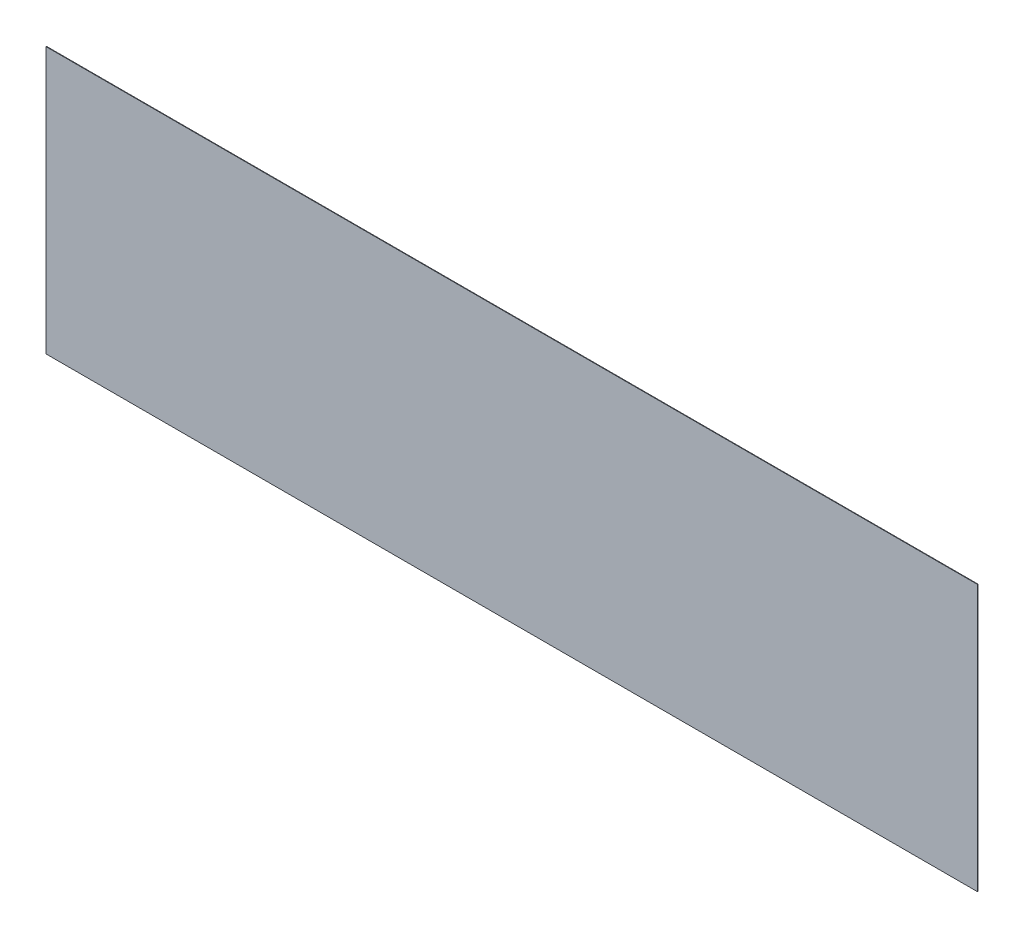
from build123d import *

# Parameters (mm, degrees)
SKETCH1_W           = 70
SKETCH1_H           = 20
BOSS_EXTRUDE1_DEPTH = 0.04


with BuildPart() as part:
    # Sketch1 → Boss-Extrude1 (new body)
    with BuildSketch(Plane.XY):
        with Locations((8.028485757, 4.430284858)):
            Rectangle(SKETCH1_W, SKETCH1_H)
    extrude(amount=BOSS_EXTRUDE1_DEPTH)


solid = part.part
